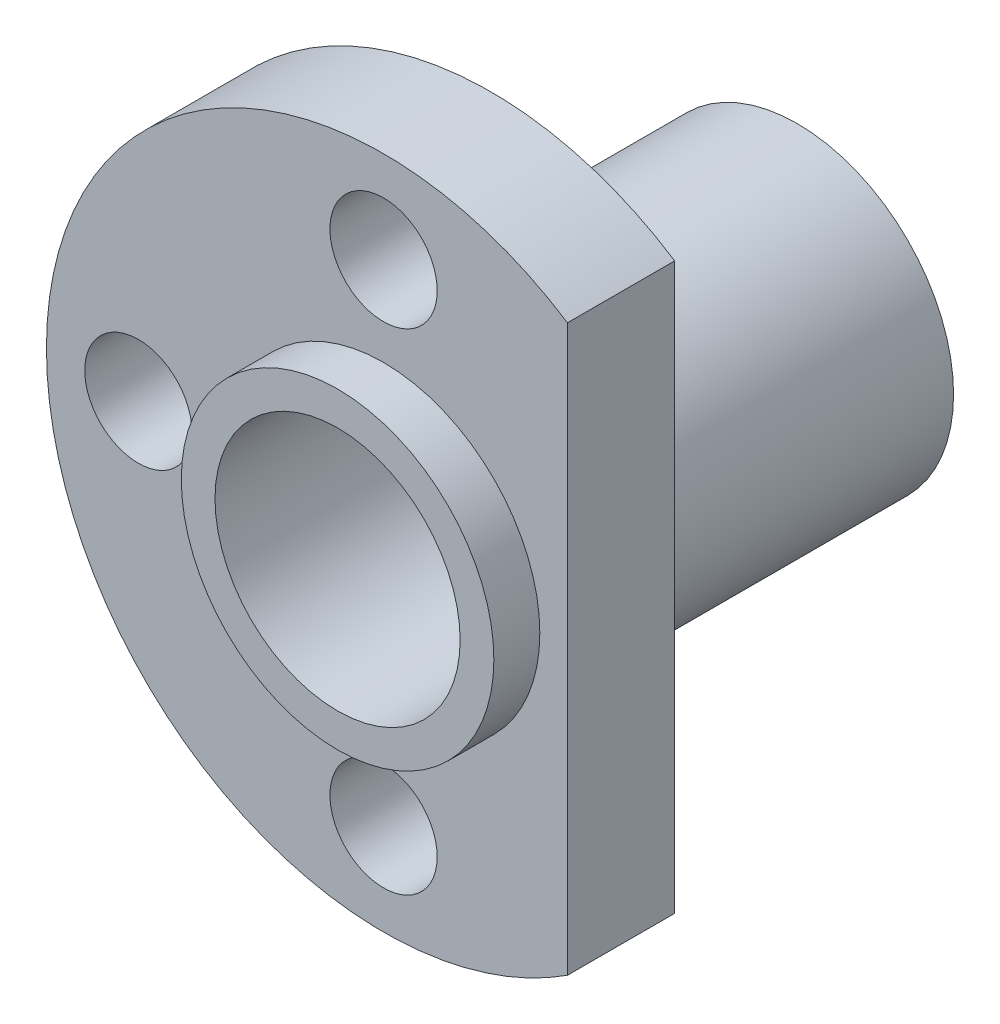
from build123d import *

# Parameters (mm, degrees)
SKETCH1_R                = 11
SKETCH1_R_2              = 5.1
SKETCH1_R_3              = 1.75
BOSS_EXTRUDE1_DEPTH      = 3.5
BOSS_EXTRUDE2_DEPTH      = 1.5
BOSS_EXTRUDE2_DEPTH_BACK = 13.5
SKETCH2_R                = 5.1
SKETCH2_R_2              = 4
CROQUIS1_W               = 13.137854129
CROQUIS1_H               = 23.868248077
CORTAR_EXTRUIR1_DEPTH    = 21.597329924


with BuildPart() as part:
    # Sketch1 → Boss-Extrude1 (new body)
    with BuildSketch(Plane.XY):
        Circle(SKETCH1_R)
        Circle(SKETCH1_R_2, mode=Mode.SUBTRACT)
        with Locations((0, 8)):
            Circle(SKETCH1_R_3, mode=Mode.SUBTRACT)
        with Locations((8, 0)):
            Circle(SKETCH1_R_3, mode=Mode.SUBTRACT)
        with Locations((0, -8)):
            Circle(SKETCH1_R_3, mode=Mode.SUBTRACT)
        with Locations((-8, 0)):
            Circle(SKETCH1_R_3, mode=Mode.SUBTRACT)
    extrude(amount=-BOSS_EXTRUDE1_DEPTH)

    # Sketch2 → Boss-Extrude2 (add, two sides: drawn at the far end of the back side and taken through both)
    with BuildSketch(Plane.XY.offset(-BOSS_EXTRUDE2_DEPTH_BACK)):
        Circle(SKETCH2_R)
        Circle(SKETCH2_R_2, mode=Mode.SUBTRACT)
    extrude(amount=BOSS_EXTRUDE2_DEPTH + BOSS_EXTRUDE2_DEPTH_BACK)

    # Croquis1 → Cortar-Extruir1 (cut, through all)
    with BuildSketch(Plane.XY):
        with Locations((12.568927065, 0.450129168)):
            Rectangle(CROQUIS1_W, CROQUIS1_H)
    extrude(amount=-CORTAR_EXTRUIR1_DEPTH, mode=Mode.SUBTRACT)


solid = part.part
